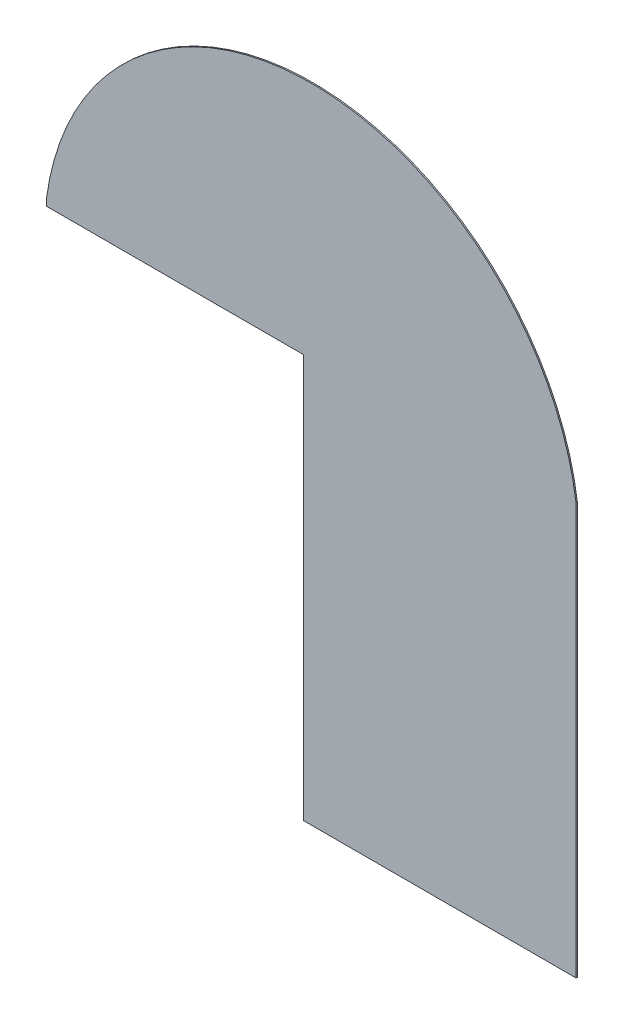
from build123d import *

# Parameters (mm, degrees)
BOSS_EXTRUDE1_DEPTH = 2.5
SKETCH2_W           = 1000
SKETCH2_H           = 1570
CUT_EXTRUDE2_DEPTH  = 6


with BuildPart() as part:
    # Sketch1 → Boss-Extrude1 (new body, symmetric)
    with BuildSketch(Plane.XY):
        with BuildLine():
            Line((1030, 800), (1030, -800))
            Line((1030, -800), (-1030, -800))
            Line((-1030, -800), (-1030, 800))
            ThreePointArc((-1030, 800), (0, 1700), (1030, 800))
        make_face()
    extrude(amount=BOSS_EXTRUDE1_DEPTH, both=True)

    # Sketch2 → Cut-Extrude2 (cut, through all)
    with BuildSketch(Plane.XY.offset(2.5)):
        with Locations((-530, -15)):
            Rectangle(SKETCH2_W, SKETCH2_H)
    extrude(amount=-CUT_EXTRUDE2_DEPTH, mode=Mode.SUBTRACT)


solid = part.part
